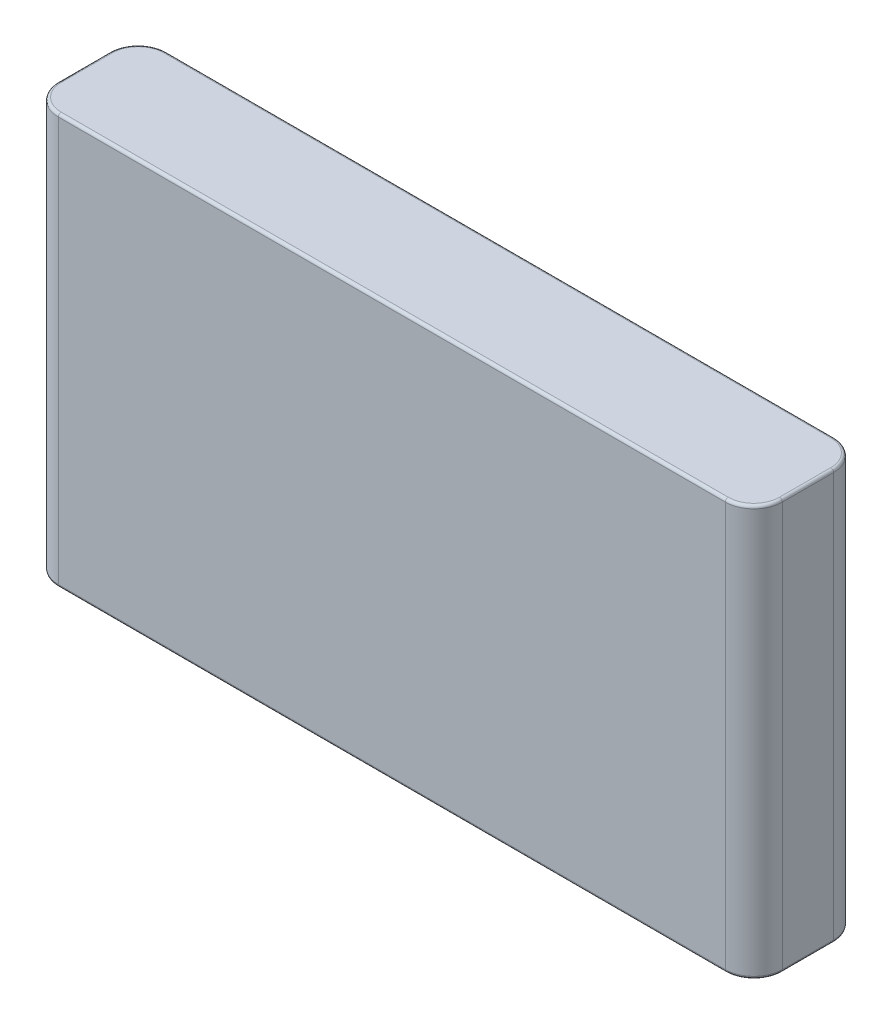
from build123d import *

# Parameters (mm, degrees)
ESQUISSE1_W        = 127
ESQUISSE1_H        = 72
BOSS_EXTRU_1_DEPTH = 19
CONG_1_R           = 5
CONG_2_R           = 0.5


with BuildPart() as part:
    # Esquisse1 → Boss.-Extru.1 (new body)
    with BuildSketch(Plane.XY):
        Rectangle(ESQUISSE1_W, ESQUISSE1_H)
    extrude(amount=BOSS_EXTRU_1_DEPTH)

    # Congé1
    cong_1_edges = [part.edges().sort_by_distance(p)[0] for p in [
        (-63.5, 0, 19),
        (63.5, 0, 19),
        (-63.5, 0, 0),
        (63.5, 0, 0),
    ]]
    fillet(cong_1_edges, radius=CONG_1_R)

    # Congé2
    cong_2_edges = [part.edges().sort_by_distance(p)[0] for p in [
        (63.5, 36, 9.5),
        (63.5, -36, 9.5),
        (0, 36, 0),
        (-63.5, 36, 9.5),
        (0, 36, 19),
        (-62.035533906, 36, 17.535533906),
        (-62.035533906, 36, 1.464466094),
        (62.035533906, 36, 17.535533906),
        (62.035533906, 36, 1.464466094),
        (0, -36, 0),
        (0, -36, 19),
        (-63.5, -36, 9.5),
        (-62.035533906, -36, 17.535533906),
        (-62.035533906, -36, 1.464466094),
        (62.035533906, -36, 17.535533906),
        (62.035533906, -36, 1.464466094),
    ]]
    fillet(cong_2_edges, radius=CONG_2_R)


solid = part.part
